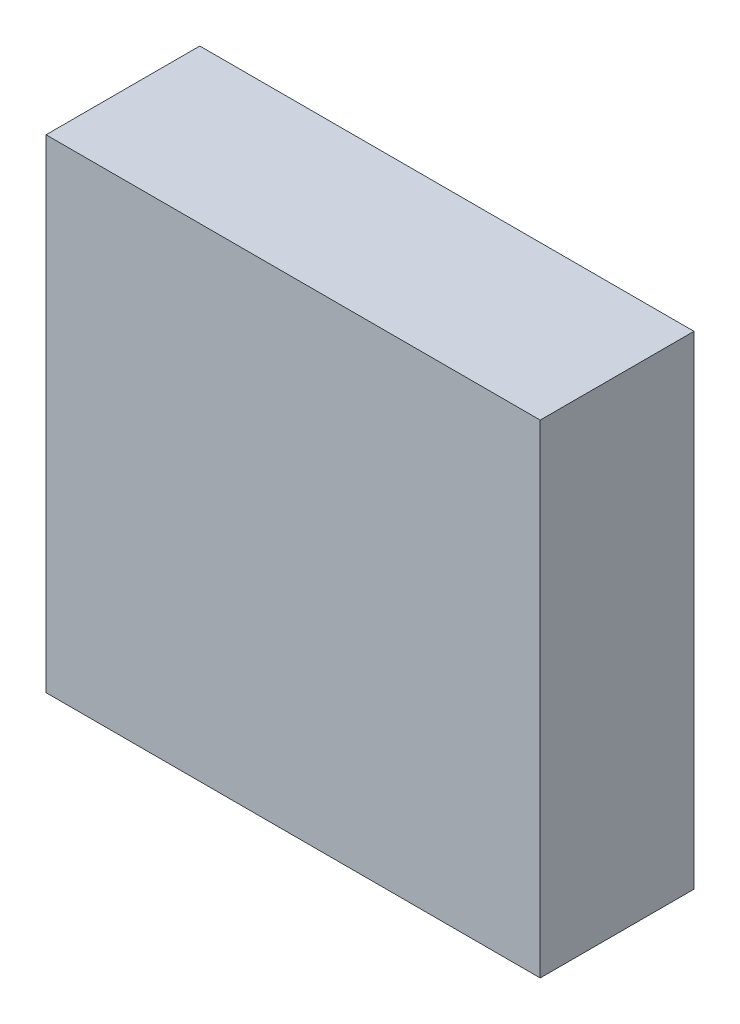
from build123d import *

# Parameters (mm, degrees)
SKETCH1_W           = 114.3
SKETCH1_H           = 111.76
BOSS_EXTRUDE1_DEPTH = 17.78


with BuildPart() as part:
    # Sketch1 → Boss-Extrude1 (new body, symmetric)
    with BuildSketch(Plane.XY):
        Rectangle(SKETCH1_W, SKETCH1_H)
    extrude(amount=BOSS_EXTRUDE1_DEPTH, both=True)


solid = part.part
